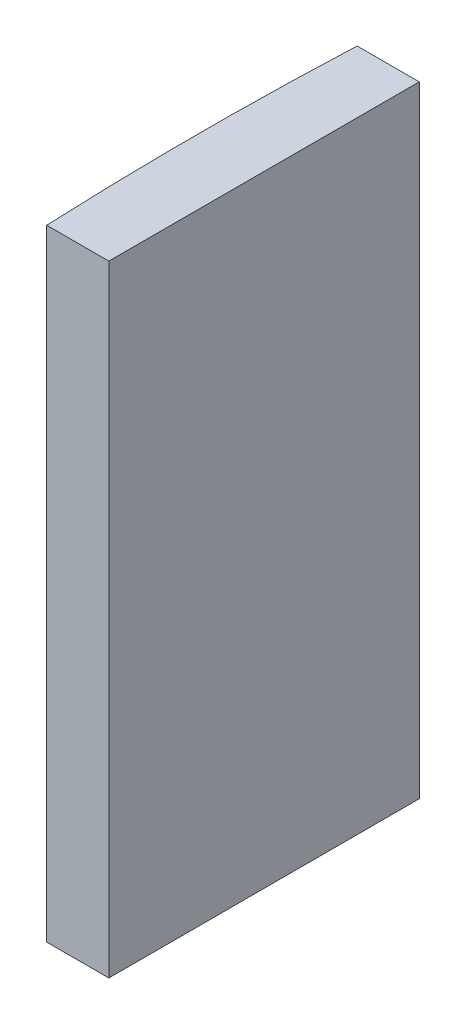
from build123d import *

# Parameters (mm, degrees)
EXTRUDE_1_DEPTH = 20


with BuildPart() as part:
    # 草图1 → 凸台-拉伸1 (new body)
    with BuildSketch(Plane(origin=(0, 0, 0), x_dir=(1, 0, 0), z_dir=(0, 1, 0))):
        with BuildLine():
            Line((-110.155687724, 5), (-108.154795665, 5))
            Line((-108.154795665, 5), (-108.154795665, -5))
            Line((-108.154795665, -5), (-110.155687724, -5))
            ThreePointArc((-110.155687724, -5), (-110.264795665, 0), (-110.155687724, 5))
        make_face()
    extrude(amount=EXTRUDE_1_DEPTH)


solid = part.part
